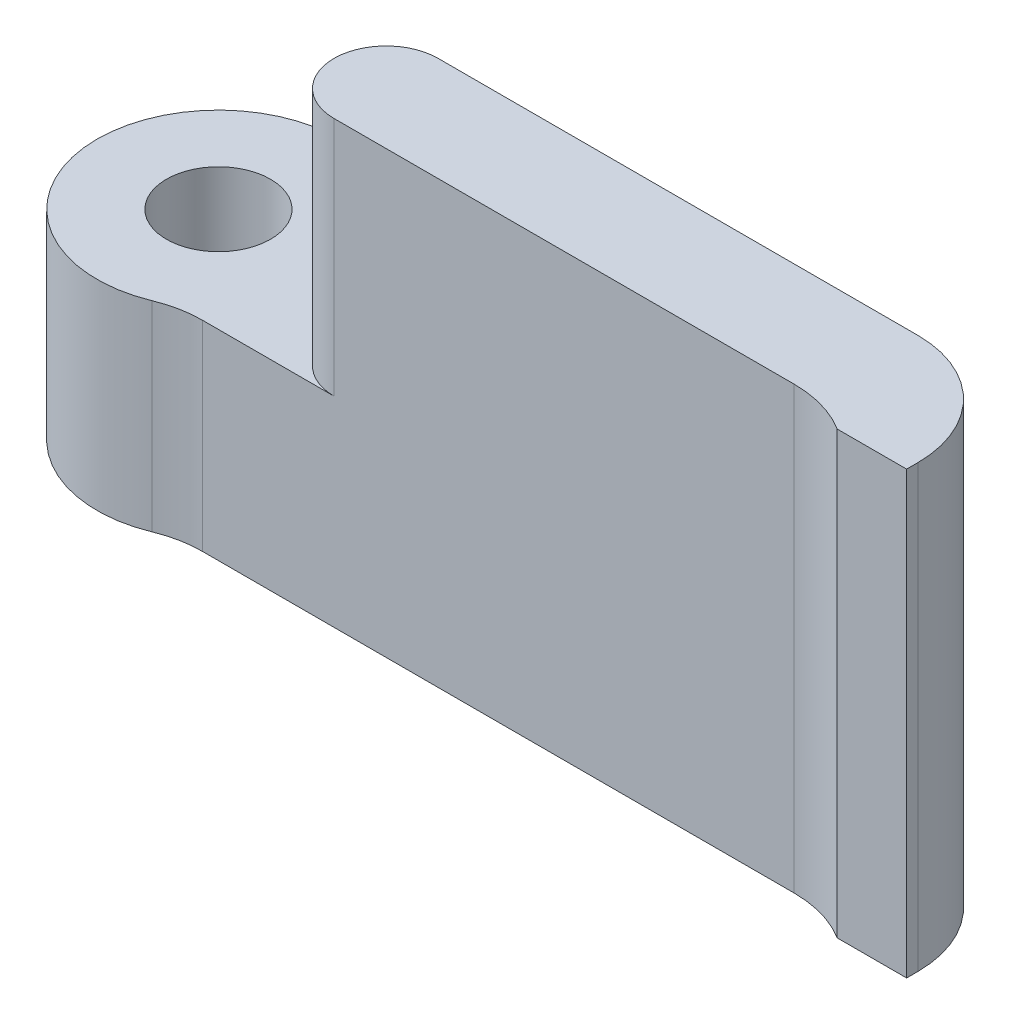
from build123d import *

# Parameters (mm, degrees)
SKETCH1_R           = 3.5
BOSS_EXTRUDE1_DEPTH = 12.7
CUT_EXTRUDE1_DEPTH  = 6.93
SKETCH3_R           = 1.5
CUT_EXTRUDE2_DEPTH  = 6.77
SKETCH4_R           = 2
CUT_EXTRUDE3_DEPTH  = 10
SKETCH5_W           = 2
SKETCH5_H           = 0.5
BOSS_EXTRUDE2_DEPTH = 12.7
FILLET1_R           = 3.175
SKETCH6_R           = 1.585
CUT_EXTRUDE4_DEPTH  = 1.5


with BuildPart() as part:
    # Sketch1 → Boss-Extrude1 (new body)
    with BuildSketch(Plane(origin=(0, 0, 0), x_dir=(1, 0, 0), z_dir=(0, 1, 0))):
        Circle(SKETCH1_R)
        with BuildLine():
            ThreePointArc((1.802775638, 3), (3.046285831, 1.723410176), (3.5, 0))
            Line((3.5, 0), (23.330212793, 0))
            Line((23.330212793, 0), (23.330212793, 3))
            Line((23.330212793, 3), (1.802775638, 3))
        make_face()
    extrude(amount=BOSS_EXTRUDE1_DEPTH)

    # Sketch2 → Cut-Extrude1 (cut)
    with BuildSketch(Plane(origin=(0, 12.7, 0), x_dir=(1, 0, 0), z_dir=(0, 1, 0))):
        with BuildLine():
            ThreePointArc((6.330212793, 3), (-6.149926342, 1.5), (6.330212793, 0))
            Line((6.330212793, 0), (3.5, 0))
            ThreePointArc((3.5, 0), (-3.046285831, -1.723410176), (1.802775638, 3))
            Line((1.802775638, 3), (6.330212793, 3))
        make_face()
        with BuildLine():
            Line((3.5, 0), (6.330212793, 0))
            ThreePointArc((6.330212793, 0), (4.830212793, 1.5), (6.330212793, 3))
            Line((6.330212793, 3), (1.802775638, 3))
            ThreePointArc((1.802775638, 3), (-3.046285831, -1.723410176), (3.5, 0))
        make_face()
    extrude(amount=-CUT_EXTRUDE1_DEPTH, mode=Mode.SUBTRACT)

    # Sketch3 → Cut-Extrude2 (cut, through all)
    with BuildSketch(Plane(origin=(0, 5.77, 0), x_dir=(1, 0, 0), z_dir=(0, 1, 0))):
        with Locations(Location((0, 0, 0), (0, 0, 270))):  # turned: the seam where the file's is
            Circle(SKETCH3_R)
    extrude(amount=-CUT_EXTRUDE2_DEPTH, mode=Mode.SUBTRACT)


with BuildPart() as body_2:
    # Mirror1: mirrored copy
    add(part.part.mirror(Plane.XY.offset(-5)))

    # Sketch4 → Cut-Extrude3 (cut)
    with BuildSketch(Plane.XY.offset(-7)):
        with Locations((59.285262001, -42.831378851)):
            Circle(SKETCH4_R)
        with Locations((59.285262001, -47.531378851)):
            Circle(SKETCH4_R)
    extrude(amount=-CUT_EXTRUDE3_DEPTH, mode=Mode.SUBTRACT)

    # Sketch5 → Boss-Extrude2 (add)
    with BuildSketch(Plane(origin=(0, 12.7, 0), x_dir=(1, 0, 0), z_dir=(0, 1, 0))):
        with BuildLine():
            Line((21.330212793, 6.5), (21.330212793, 7))
            Line((21.330212793, 7), (19.59096008, 7))
            ThreePointArc((19.59096008, 7), (20.495808134, 6.872518864), (21.330212793, 6.5))
        make_face()
        with Locations((22.330212793, 6.75)):
            Rectangle(SKETCH5_W, SKETCH5_H)
    extrude(amount=-BOSS_EXTRUDE2_DEPTH)

    # Fillet1
    fillet1_edges = [body_2.edges().sort_by_distance(p)[0] for p in [
        (1.802775638, 2.885, -7),
        (3.5, 2.885, -10),
        (23.330212793, 6.35, -10),
    ]]
    fillet(fillet1_edges, radius=FILLET1_R)

    # Sketch6 → Cut-Extrude4 (cut)
    with BuildSketch(Plane.XY.offset(-7)):
        with Locations((66.743933259, -45.181378851)):
            Circle(SKETCH6_R)
    extrude(amount=-CUT_EXTRUDE4_DEPTH, mode=Mode.SUBTRACT)


solid = body_2.part
